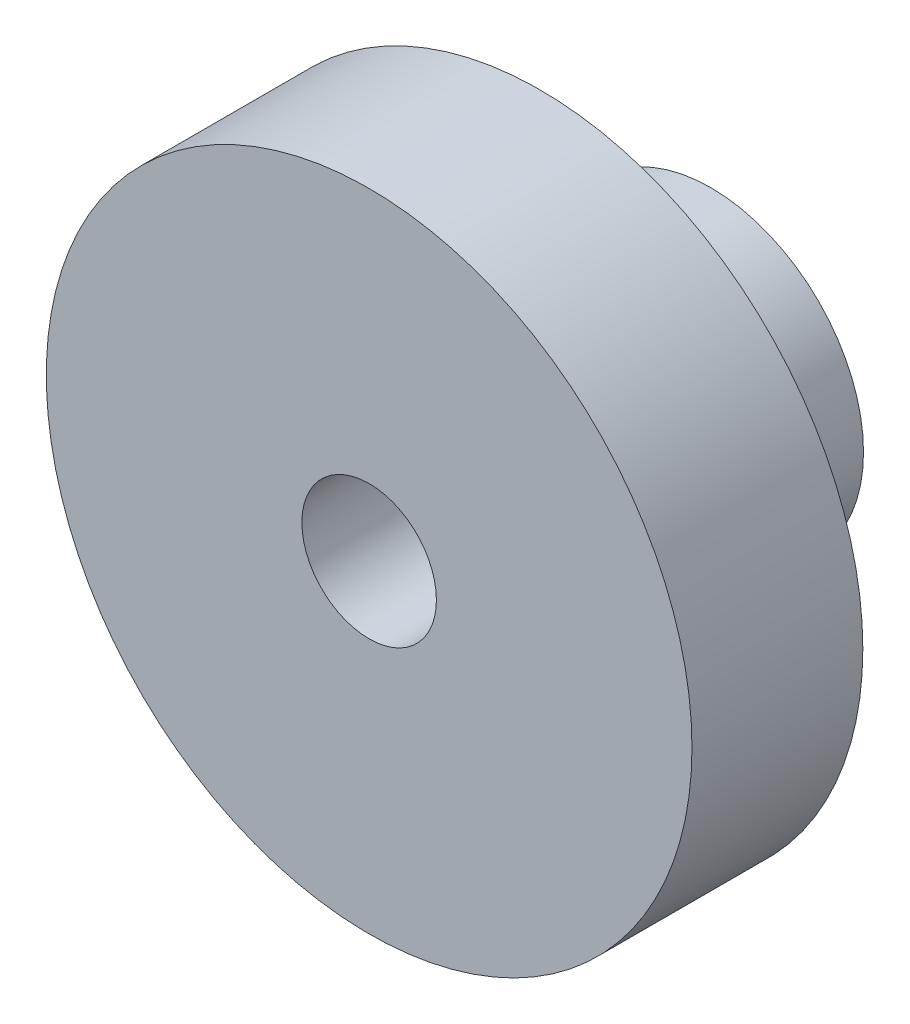
from build123d import *

# Parameters (mm, degrees)
SKETCH1_R           = 12
SKETCH1_R_2         = 2.5
BOSS_EXTRUDE1_DEPTH = 6.35
SKETCH2_R           = 5.675
SKETCH2_R_2         = 2.5
BOSS_EXTRUDE2_DEPTH = 6.35
SKETCH3_R           = 5.675
SKETCH3_R_2         = 1.5875
BOSS_EXTRUDE3_DEPTH = 1.5875


with BuildPart() as part:
    # Sketch1 → Boss-Extrude1 (new body)
    with BuildSketch(Plane.XY):
        Circle(SKETCH1_R)
        Circle(SKETCH1_R_2, mode=Mode.SUBTRACT)
    extrude(amount=BOSS_EXTRUDE1_DEPTH)

    # Sketch2 → Boss-Extrude2 (add)
    with BuildSketch(Plane(origin=(0, 0, 0), x_dir=(-1, 0, 0), z_dir=(0, 0, -1))):
        Circle(SKETCH2_R)
        Circle(SKETCH2_R_2, mode=Mode.SUBTRACT)
    extrude(amount=BOSS_EXTRUDE2_DEPTH)

    # Sketch3 → Boss-Extrude3 (add)
    with BuildSketch(Plane(origin=(0, 0, -6.35), x_dir=(-1, 0, 0), z_dir=(0, 0, -1))):
        Circle(SKETCH3_R)
        Circle(SKETCH3_R_2, mode=Mode.SUBTRACT)
    extrude(amount=-BOSS_EXTRUDE3_DEPTH)


solid = part.part
